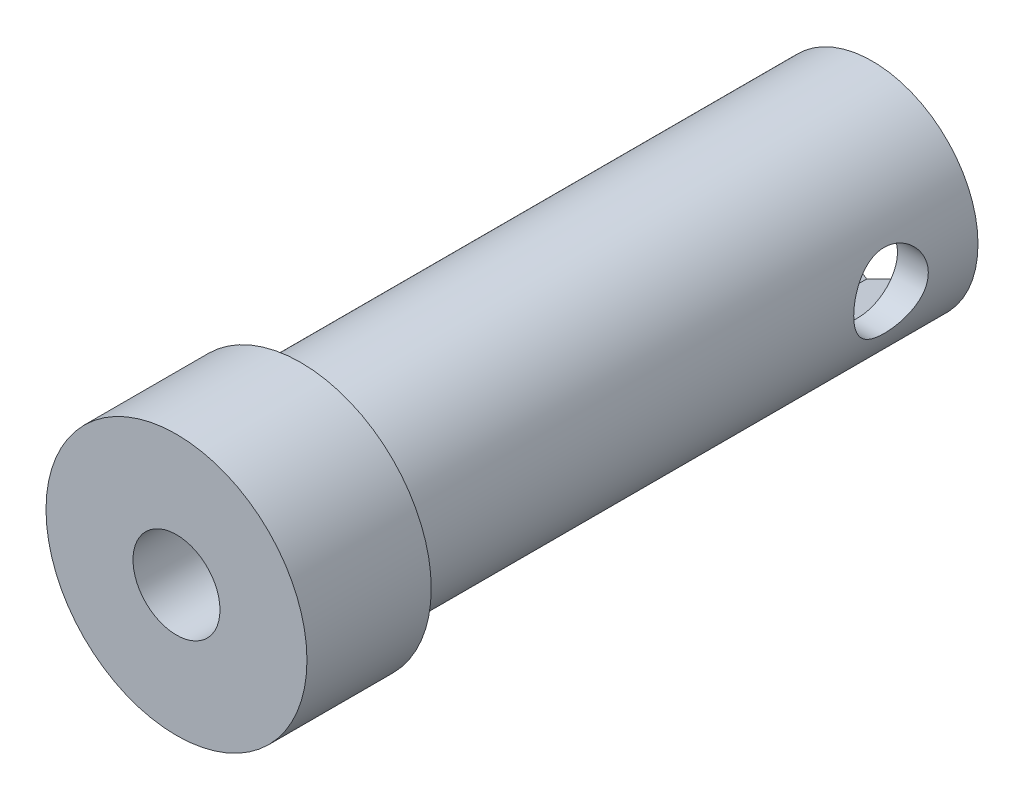
from build123d import *

# Parameters (mm, degrees)
SKETCH1_R           = 4.25
BOSS_EXTRUDE1_DEPTH = 23
SKETCH2_R           = 5.25
BOSS_EXTRUDE2_DEPTH = 5
SKETCH6_R           = 1.5
CUT_EXTRUDE3_DEPTH  = 2
SKETCH7_R           = 1.75
CUT_EXTRUDE4_DEPTH  = 29.0000001
CUT_EXTRUDE5_DEPTH  = 4


with BuildPart() as part:
    # Sketch1 → Boss-Extrude1 (new body)
    with BuildSketch(Plane.XY):
        Circle(SKETCH1_R)
    extrude(amount=BOSS_EXTRUDE1_DEPTH)

    # Sketch2 → Boss-Extrude2 (add)
    with BuildSketch(Plane.XY.offset(23)):
        Circle(SKETCH2_R)
    extrude(amount=BOSS_EXTRUDE2_DEPTH)

    # Sketch6 → Cut-Extrude3 (cut)
    with BuildSketch(Plane(origin=(4.25, 0, 0), x_dir=(0, 0, -1), z_dir=(1, 0, 0))):
        with Locations((-3.5, 0)):
            Circle(SKETCH6_R)
    extrude(amount=-CUT_EXTRUDE3_DEPTH, mode=Mode.SUBTRACT)

    # Sketch7 → Cut-Extrude4 (cut, through all)
    with BuildSketch(Plane.XY.offset(28)):
        Circle(SKETCH7_R)
    extrude(amount=-CUT_EXTRUDE4_DEPTH, mode=Mode.SUBTRACT)

    # Sketch8 → Cut-Extrude5 (cut)
    with BuildSketch(Plane(origin=(0, 0, 0), x_dir=(-1, 0, 0), z_dir=(0, 0, -1))):
        Polygon((-0.22790745, 3.456596331), (-3.107453958, 1.530924524), (-2.879546508, -1.925671807), (0.22790745, -3.456596331), (3.107453958, -1.530924524), (2.879546508, 1.925671807), align=None)
    extrude(amount=-CUT_EXTRUDE5_DEPTH, mode=Mode.SUBTRACT)


solid = part.part
